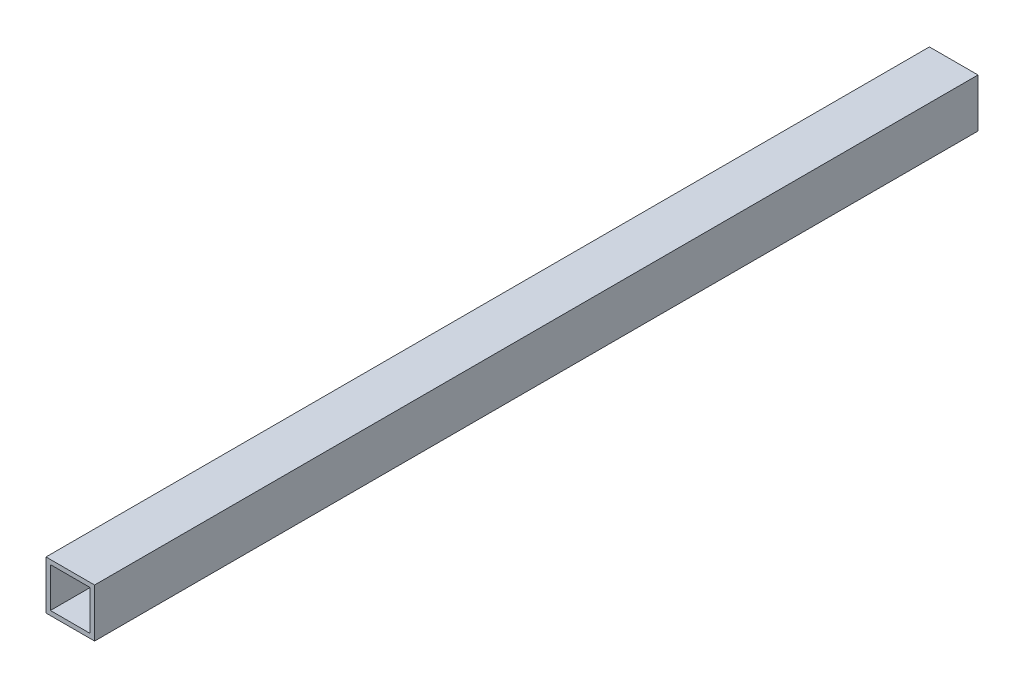
from build123d import *

# Parameters (mm, degrees)
SKETCH2_W           = 44
SKETCH2_H           = 44
SKETCH2_W_2         = 36
SKETCH2_H_2         = 36
EXTRUDE_THIN1_DEPTH = 400


with BuildPart() as part:
    # Sketch2 → Extrude-Thin1 (new body, symmetric)
    with BuildSketch(Plane.XY):
        with Locations((-18.705882353, 19.029411765)):
            Rectangle(SKETCH2_W, SKETCH2_H)
        with Locations((-18.705882353, 19.029411765)):
            Rectangle(SKETCH2_W_2, SKETCH2_H_2, mode=Mode.SUBTRACT)
    extrude(amount=EXTRUDE_THIN1_DEPTH, both=True)


solid = part.part
